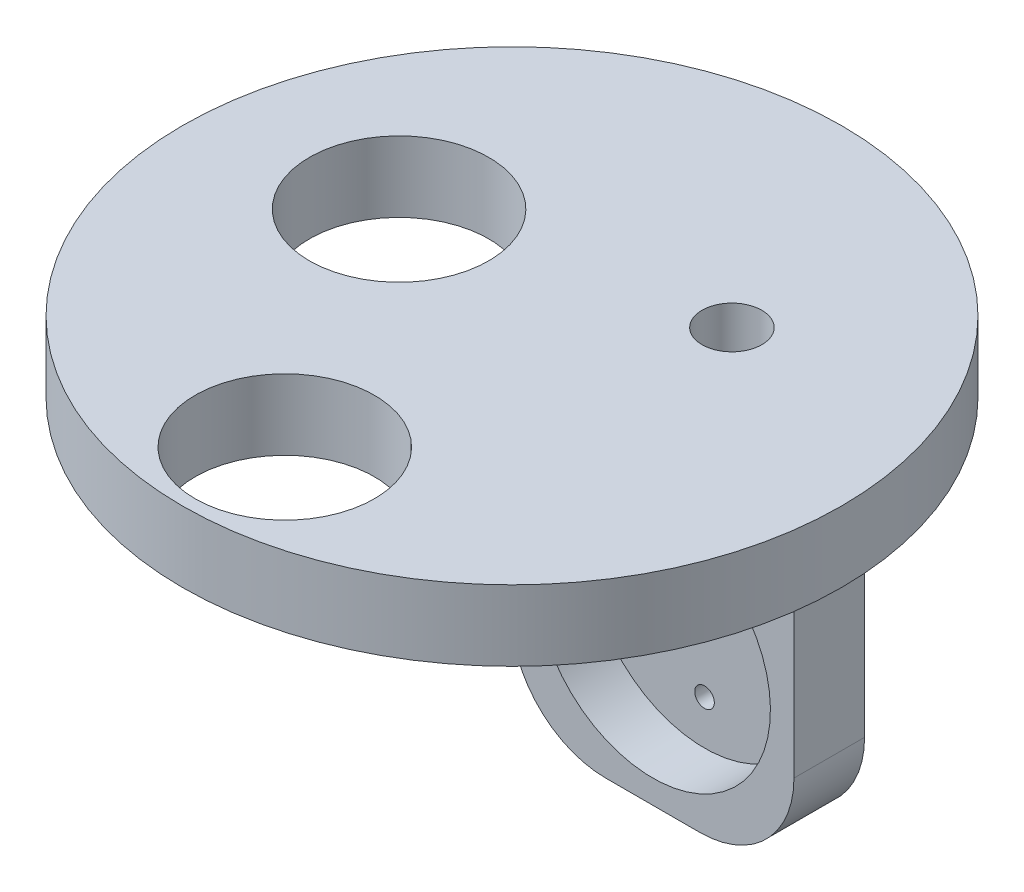
from build123d import *

# Parameters (mm, degrees)
SKETCH1_W           = 30
SKETCH1_H           = 45
BOSS_EXTRUDE1_DEPTH = 7.5
SKETCH2_R           = 12.5
CUT_EXTRUDE1_DEPTH  = 5.5
CUT_EXTRUDE2_REACH  = 4
SKETCH4_R           = 1.039999008
FILLET1_R           = 10
CUT_EXTRUDE3_REACH  = 9.5
SKETCH6_W           = 3.5
SKETCH6_H           = 34.5
SKETCH9_R           = 35
BOSS_EXTRUDE3_DEPTH = 7.5
CUT_EXTRUDE4_REACH  = 54.5
SKETCH10_R          = 9.525
SKETCH10_R_2        = 3.175


with BuildPart() as part:
    # Sketch1 → Boss-Extrude1 (new body)
    with BuildSketch(Plane.XY):
        Rectangle(SKETCH1_W, SKETCH1_H)
    extrude(amount=BOSS_EXTRUDE1_DEPTH)

    # Sketch2 → Cut-Extrude1 (cut)
    with BuildSketch(Plane.XY.offset(7.5)):
        with Locations((0, -7.5)):
            Circle(SKETCH2_R)
    extrude(amount=-CUT_EXTRUDE1_DEPTH, mode=Mode.SUBTRACT)

    # Sketch4 → Cut-Extrude2 (cut, up to next)
    with BuildSketch(Plane.XY.offset(2), mode=Mode.PRIVATE) as cut_extrude2_sk1:
        with Locations((0, -15.300000992)):
            Circle(SKETCH4_R)
    cut_extrude2_tool1 = extrude(cut_extrude2_sk1.sketch, amount=-CUT_EXTRUDE2_REACH, mode=Mode.PRIVATE) & part.part
    add(cut_extrude2_tool1.solids().sort_by_distance((0, -15.300001, 2))[0], mode=Mode.SUBTRACT)
    # Sketch4 → Cut-Extrude2 (cut, up to next)
    with BuildSketch(Plane.XY.offset(2), mode=Mode.PRIVATE) as cut_extrude2_sk2:
        with Locations((6.754999008, -3.599999504)):
            Circle(SKETCH4_R)
    cut_extrude2_tool2 = extrude(cut_extrude2_sk2.sketch, amount=-CUT_EXTRUDE2_REACH, mode=Mode.PRIVATE) & part.part
    add(cut_extrude2_tool2.solids().sort_by_distance((6.754999, -3.6, 2))[0], mode=Mode.SUBTRACT)
    # Sketch4 → Cut-Extrude2 (cut, up to next)
    with BuildSketch(Plane.XY.offset(2), mode=Mode.PRIVATE) as cut_extrude2_sk3:
        with Locations((-6.754999008, -3.599999504)):
            Circle(SKETCH4_R)
    cut_extrude2_tool3 = extrude(cut_extrude2_sk3.sketch, amount=-CUT_EXTRUDE2_REACH, mode=Mode.PRIVATE) & part.part
    add(cut_extrude2_tool3.solids().sort_by_distance((-6.754999, -3.6, 2))[0], mode=Mode.SUBTRACT)

    # Fillet1
    fillet1_edges = [part.edges().sort_by_distance(p)[0] for p in [
        (15, -22.5, 3.75),
        (-15, -22.5, 3.75),
    ]]
    fillet(fillet1_edges, radius=FILLET1_R)

    # Sketch6 → Cut-Extrude3 (cut, up to next)
    with BuildSketch(Plane.XY.offset(7.5), mode=Mode.PRIVATE) as cut_extrude3_sk1:
        with Locations((0, 9.75)):
            Rectangle(SKETCH6_W, SKETCH6_H)
    cut_extrude3_tool1 = extrude(cut_extrude3_sk1.sketch, amount=-CUT_EXTRUDE3_REACH, mode=Mode.PRIVATE) & part.part
    add(cut_extrude3_tool1.solids().sort_by_distance((0, 9.75, 7.5))[0], mode=Mode.SUBTRACT)

    # Sketch9 → Boss-Extrude3 (add)
    with BuildSketch(Plane(origin=(0, 22.5, 0), x_dir=(1, 0, 0), z_dir=(0, 1, 0))):
        with Locations((0, -22.449944321)):
            Circle(SKETCH9_R)
    extrude(amount=BOSS_EXTRUDE3_DEPTH)

    # Sketch10 → Cut-Extrude4 (cut, up to next)
    with BuildSketch(Plane(origin=(0, 30, 0), x_dir=(1, 0, 0), z_dir=(0, 1, 0)), mode=Mode.PRIVATE) as cut_extrude4_sk1:
        with Locations((0, -46.585066781)):
            Circle(SKETCH10_R)
    cut_extrude4_tool1 = extrude(cut_extrude4_sk1.sketch, amount=-CUT_EXTRUDE4_REACH, mode=Mode.PRIVATE) & part.part
    add(cut_extrude4_tool1.solids().sort_by_distance((0, 30, 46.585067))[0], mode=Mode.SUBTRACT)
    # Sketch10 → Cut-Extrude4 (cut, up to next)
    with BuildSketch(Plane(origin=(0, 30, 0), x_dir=(1, 0, 0), z_dir=(0, 1, 0)), mode=Mode.PRIVATE) as cut_extrude4_sk2:
        with Locations((-15.813770298, -18.629568863)):
            Circle(SKETCH10_R)
    cut_extrude4_tool2 = extrude(cut_extrude4_sk2.sketch, amount=-CUT_EXTRUDE4_REACH, mode=Mode.PRIVATE) & part.part
    add(cut_extrude4_tool2.solids().sort_by_distance((-15.81377, 30, 18.629569))[0], mode=Mode.SUBTRACT)
    # Sketch10 → Cut-Extrude4 (cut, up to next)
    with BuildSketch(Plane(origin=(0, 30, 0), x_dir=(1, 0, 0), z_dir=(0, 1, 0)), mode=Mode.PRIVATE) as cut_extrude4_sk3:
        with Locations((12.753899309, -11.844380068)):
            Circle(SKETCH10_R_2)
    cut_extrude4_tool3 = extrude(cut_extrude4_sk3.sketch, amount=-CUT_EXTRUDE4_REACH, mode=Mode.PRIVATE) & part.part
    add(cut_extrude4_tool3.solids().sort_by_distance((12.753899, 30, 11.84438))[0], mode=Mode.SUBTRACT)


solid = part.part
